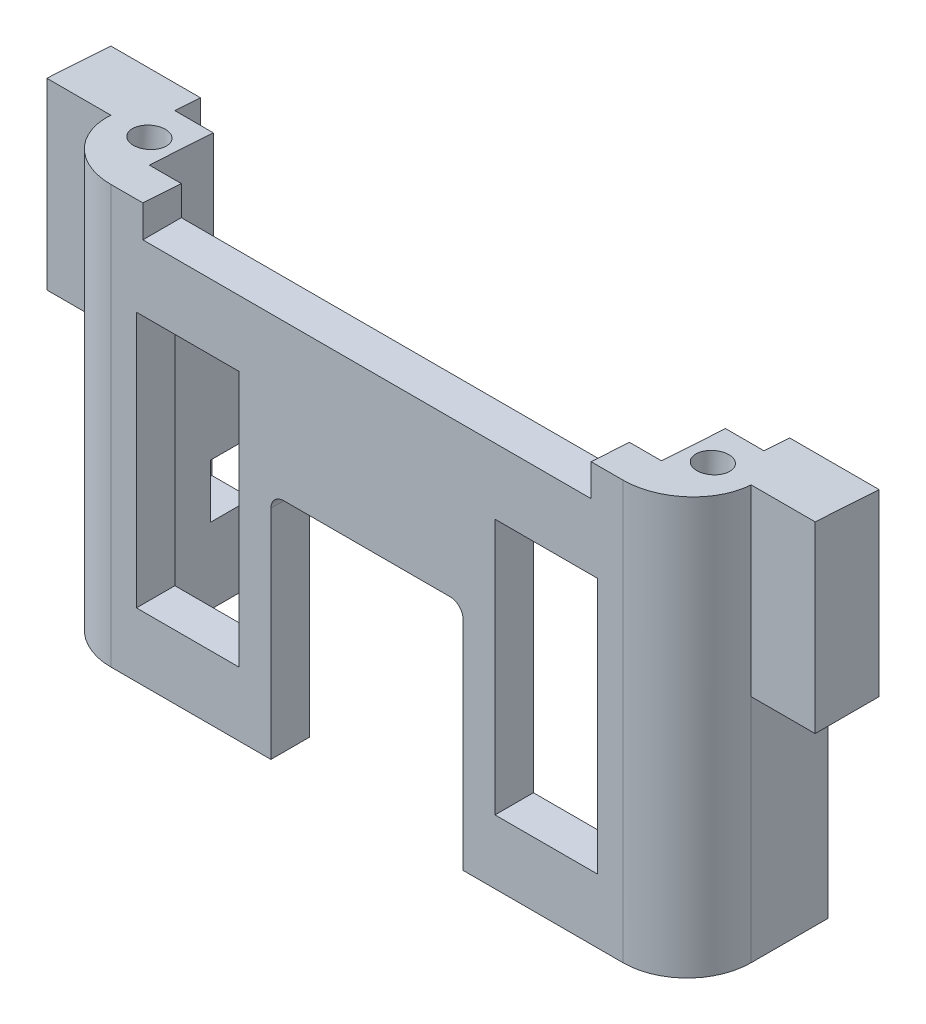
from build123d import *

# Parameters (mm, degrees)
BOSS_EXTRUDE1_DEPTH = 16.32
SKETCH3_W           = 8
SKETCH3_H           = 20
SKETCH3_W_2         = 15
SKETCH3_H_2         = 18
CUT_EXTRUDE1_DEPTH  = 4
SKETCH4_W           = 1
SKETCH4_H           = 19.64
CUT_EXTRUDE2_DEPTH  = 27.5
FILLET1_R           = 5
CUT_EXTRUDE3_DEPTH  = 26
BOSS_EXTRUDE2_START = -25
BOSS_EXTRUDE2_DEPTH = 5
BOSS_EXTRUDE3_START = 25
BOSS_EXTRUDE3_DEPTH = 5
SKETCH7_R           = 1.25
CUT_EXTRUDE4_DEPTH  = 5
SKETCH8_W           = 35
SKETCH8_H           = 5
CUT_EXTRUDE5_DEPTH  = 5
CUT_EXTRUDE6_START  = -10
SKETCH9_W           = 2.2
SKETCH9_H           = 5.2
CUT_EXTRUDE6_DEPTH  = 3.2
CUT_EXTRUDE7_START  = -16.32
SKETCH10_R          = 1.25
CUT_EXTRUDE7_DEPTH  = 5
CUT_EXTRUDE8_START  = -11
SKETCH11_W          = 3.2
SKETCH11_H          = 4.2
CUT_EXTRUDE8_DEPTH  = 3.2
CUT_EXTRUDE9_START  = 2
SKETCH12_W          = 3
SKETCH12_H          = 2
CUT_EXTRUDE9_DEPTH  = 15
FILLET3_R           = 1


with BuildPart() as part:
    # Sketch2 → Boss-Extrude1 (new body, symmetric)
    with BuildSketch(Plane(origin=(0, 0, 0), x_dir=(1, 0, 0), z_dir=(0, 1, 0))):
        Polygon((-25, 0), (25, 0), (25, 11), (20, 11), (20, 3), (-20, 3), (-20, 11), (-25, 11), align=None)
    extrude(amount=BOSS_EXTRUDE1_DEPTH, both=True)

    # Sketch3 → Cut-Extrude1 (cut)
    with BuildSketch(Plane.XY):
        with Locations((14, -1.32)):
            Rectangle(SKETCH3_W, SKETCH3_H)
        with Locations((-14, -1.32)):
            Rectangle(SKETCH3_W, SKETCH3_H)
        with Locations((0, -7.32)):
            Rectangle(SKETCH3_W_2, SKETCH3_H_2)
    extrude(amount=-CUT_EXTRUDE1_DEPTH, mode=Mode.SUBTRACT)

    # Sketch4 → Cut-Extrude2 (cut, symmetric)
    with BuildSketch(Plane(origin=(0, 0, 0), x_dir=(0, 0, -1), z_dir=(1, 0, 0))):
        with Locations((10.5, 6.5)):
            Rectangle(SKETCH4_W, SKETCH4_H)
    extrude(amount=CUT_EXTRUDE2_DEPTH, both=True, mode=Mode.SUBTRACT)

    # Fillet1
    fillet1_edges = [part.edges().sort_by_distance(p)[0] for p in [
        (25, 0, 0),
        (-25, 0, 0),
    ]]
    fillet(fillet1_edges, radius=FILLET1_R)

    # Sketch5 → Cut-Extrude3 (cut, symmetric)
    with BuildSketch(Plane(origin=(0, 0, 0), x_dir=(0, 0, -1), z_dir=(1, 0, 0))):
        Polygon((10, 16.32), (0, 16.32), (10, 15.68), align=None)
    extrude(amount=CUT_EXTRUDE3_DEPTH, both=True, mode=Mode.SUBTRACT)

    # Sketch6 → Boss-Extrude2 (add)
    with BuildSketch(Plane(origin=(0, 0, 0), x_dir=(0, 0, -1), z_dir=(1, 0, 0)).offset(BOSS_EXTRUDE2_START)):
        Polygon((10, 15.68), (5, 16), (5, 1.68), (10, 1.68), align=None)
    extrude(amount=-BOSS_EXTRUDE2_DEPTH)

    # Sketch6_2 → Boss-Extrude3 (add)
    with BuildSketch(Plane(origin=(0, 0, 0), x_dir=(0, 0, -1), z_dir=(1, 0, 0)).offset(BOSS_EXTRUDE3_START)):
        Polygon((10, 15.68), (5, 16), (5, 1.68), (10, 1.68), align=None)
    extrude(amount=BOSS_EXTRUDE3_DEPTH)

    # Sketch7 → Cut-Extrude4 (cut)
    with BuildSketch(Plane(origin=(0, 16.253425967, -1.040219262), x_dir=(1, 0, 0), z_dir=(0, 0.99795827, -0.063869329))):
        with Locations((22, 3.978111617)):
            Circle(SKETCH7_R)
        with Locations((-22, 3.978111617)):
            Circle(SKETCH7_R)
    extrude(amount=-CUT_EXTRUDE4_DEPTH, mode=Mode.SUBTRACT)

    # Sketch8 → Cut-Extrude5 (cut)
    with BuildSketch(Plane.XY):
        with Locations((0, 16.32)):
            Rectangle(SKETCH8_W, SKETCH8_H)
    extrude(amount=-CUT_EXTRUDE5_DEPTH, mode=Mode.SUBTRACT)

    # Sketch9 → Cut-Extrude6 (cut)
    with BuildSketch(Plane.XY.offset(CUT_EXTRUDE6_START)):
        with Locations((-27, 7.18)):
            Rectangle(SKETCH9_W, SKETCH9_H)
        with Locations((27, 7.18)):
            Rectangle(SKETCH9_W, SKETCH9_H)
    extrude(amount=CUT_EXTRUDE6_DEPTH, mode=Mode.SUBTRACT)

    # Sketch10 → Cut-Extrude7 (cut)
    with BuildSketch(Plane(origin=(0, 0, 0), x_dir=(1, 0, 0), z_dir=(0, 1, 0)).offset(CUT_EXTRUDE7_START)):
        with Locations((-22.5, 5)):
            Circle(SKETCH10_R)
        with Locations((22.5, 5)):
            Circle(SKETCH10_R)
    extrude(amount=CUT_EXTRUDE7_DEPTH, mode=Mode.SUBTRACT)

    # Sketch11 → Cut-Extrude8 (cut)
    with BuildSketch(Plane.XY.offset(CUT_EXTRUDE8_START)):
        with Locations((21.5, -8.32)):
            Rectangle(SKETCH11_W, SKETCH11_H)
        with Locations((-21.5, -8.32)):
            Rectangle(SKETCH11_W, SKETCH11_H)
    extrude(amount=CUT_EXTRUDE8_DEPTH, mode=Mode.SUBTRACT)

    # Sketch12 → Cut-Extrude9 (cut)
    with BuildSketch(Plane(origin=(0, 0, 0), x_dir=(1, 0, 0), z_dir=(0, 1, 0)).offset(CUT_EXTRUDE9_START)):
        with Locations((21.5, 9)):
            Rectangle(SKETCH12_W, SKETCH12_H)
        with Locations((-21.5, 9)):
            Rectangle(SKETCH12_W, SKETCH12_H)
    extrude(amount=CUT_EXTRUDE9_DEPTH, mode=Mode.SUBTRACT)

    # Fillet3
    fillet3_edges = [part.edges().sort_by_distance(p)[0] for p in [
        (-7.5, 1.68, -1.5),
        (7.5, 1.68, -1.5),
    ]]
    fillet(fillet3_edges, radius=FILLET3_R)


solid = part.part
